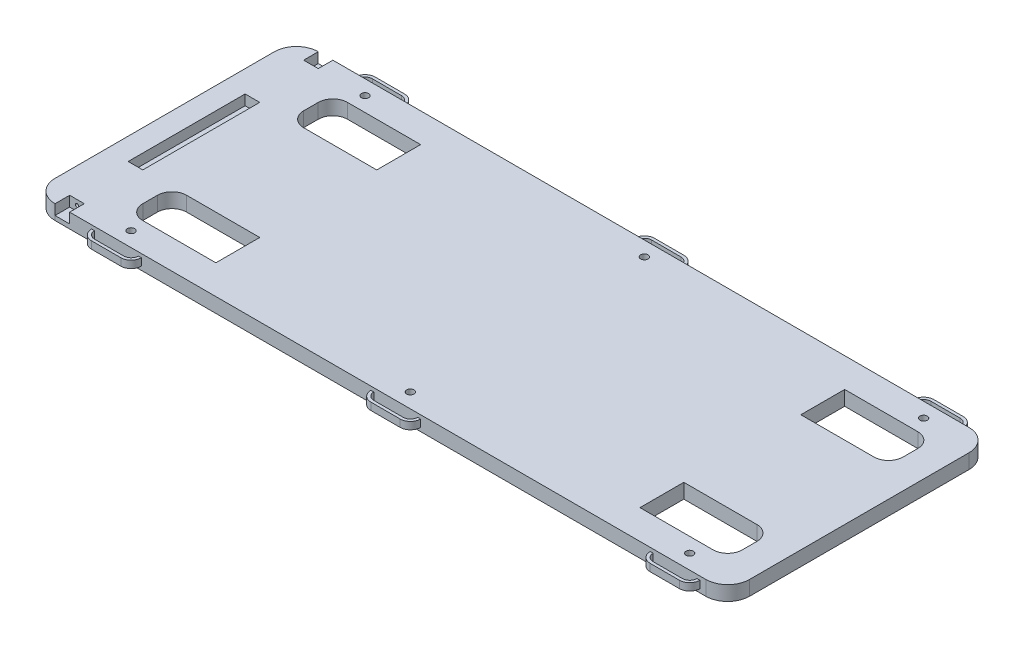
from build123d import *

# Parameters (mm, degrees)
BOSS_EXTRUDE1_DEPTH     = 12.7
BACKREST_BRACKET_SLOT_W = 12.7
BACKREST_BRACKET_SLOT_H = 8.89
CUT_EXTRUDE3_DEPTH      = 12.7
BACKREST_SCREW_HOLE_R   = 1.397
CUT_EXTRUDE4_DEPTH      = 6.35
CUT_EXTRUDE5_DEPTH      = 25.4
BOSS_EXTRUDE2_DEPTH     = 3.175
SKETCH37_W              = 12.7
SKETCH37_H              = 101.6
CUT_EXTRUDE7_DEPTH      = 8.89
SKETCH38_R              = 3.175
CUT_EXTRUDE8_DEPTH      = 12.7


with BuildPart() as part:
    # Main Body → Boss-Extrude1 (new body)
    with BuildSketch(Plane(origin=(0, 0, 0), x_dir=(1, 0, 0), z_dir=(0, 1, 0))):
        with BuildLine():
            Line((-301.625, -95.25), (-301.625, 95.25))
            ThreePointArc((-301.625, 95.25), (-296.045384182, 108.720384182), (-282.575, 114.3))
            Line((-282.575, 114.3), (282.575, 114.3))
            ThreePointArc((282.575, 114.3), (296.045384182, 108.720384182), (301.625, 95.25))
            Line((301.625, 95.25), (301.625, -95.25))
            ThreePointArc((301.625, -95.25), (296.045384182, -108.720384182), (282.575, -114.3))
            Line((282.575, -114.3), (-282.575, -114.3))
            ThreePointArc((-282.575, -114.3), (-296.045384182, -108.720384182), (-301.625, -95.25))
        make_face()
    extrude(amount=BOSS_EXTRUDE1_DEPTH)

    # Backrest Bracket Slot → Cut-Extrude3 (cut)
    with BuildSketch(Plane.XY.offset(114.3)):
        with Locations((-276.225, 8.255)):
            Rectangle(BACKREST_BRACKET_SLOT_W, BACKREST_BRACKET_SLOT_H)
    cut_extrude3 = extrude(amount=-CUT_EXTRUDE3_DEPTH, mode=Mode.SUBTRACT)

    # Backrest Screw Hole → Cut-Extrude4 (cut)
    with BuildSketch(Plane.XY.offset(101.6)):
        with Locations((-276.225, 8.255)):
            Circle(BACKREST_SCREW_HOLE_R)
    cut_extrude4 = extrude(amount=-CUT_EXTRUDE4_DEPTH, mode=Mode.SUBTRACT)

    # Mirror1: Cut-Extrude3, Cut-Extrude4 across plane
    add(cut_extrude3.mirror(Plane.XY), mode=Mode.SUBTRACT)
    add(cut_extrude4.mirror(Plane.XY), mode=Mode.SUBTRACT)

    # Couch Foot Slits → Cut-Extrude5 (cut)
    with BuildSketch(Plane(origin=(0, 12.7, 0), x_dir=(1, 0, 0), z_dir=(0, 1, 0))):
        with BuildLine():
            Line((-231.775, 88.9), (-168.275, 88.9))
            Line((-168.275, 88.9), (-168.275, 50.8))
            Line((-168.275, 50.8), (-231.775, 50.8))
            ThreePointArc((-231.775, 50.8), (-240.755256121, 54.519743879), (-244.475, 63.5))
            Line((-244.475, 63.5), (-244.475, 76.2))
            ThreePointArc((-244.475, 76.2), (-240.755256121, 85.180256121), (-231.775, 88.9))
        make_face()
        with BuildLine():
            Line((276.225, 76.2), (276.225, 63.5))
            ThreePointArc((276.225, 63.5), (272.505256121, 54.519743879), (263.525, 50.8))
            Line((263.525, 50.8), (200.025, 50.8))
            Line((200.025, 50.8), (200.025, 88.9))
            Line((200.025, 88.9), (263.525, 88.9))
            ThreePointArc((263.525, 88.9), (272.505256121, 85.180256121), (276.225, 76.2))
        make_face()
        with BuildLine():
            Line((-231.775, -50.8), (-168.275, -50.8))
            Line((-168.275, -50.8), (-168.275, -88.9))
            Line((-168.275, -88.9), (-231.775, -88.9))
            ThreePointArc((-231.775, -88.9), (-240.755256121, -85.180256121), (-244.475, -76.2))
            Line((-244.475, -76.2), (-244.475, -63.5))
            ThreePointArc((-244.475, -63.5), (-240.755256121, -54.519743879), (-231.775, -50.8))
        make_face()
        with BuildLine():
            Line((276.225, -63.5), (276.225, -76.2))
            ThreePointArc((276.225, -76.2), (272.505256121, -85.180256121), (263.525, -88.9))
            Line((263.525, -88.9), (200.025, -88.9))
            Line((200.025, -88.9), (200.025, -50.8))
            Line((200.025, -50.8), (263.525, -50.8))
            ThreePointArc((263.525, -50.8), (272.505256121, -54.519743879), (276.225, -63.5))
        make_face()
    extrude(amount=-CUT_EXTRUDE5_DEPTH, mode=Mode.SUBTRACT)

    # Sketch24 → Boss-Extrude2 (add, symmetric)
    with BuildSketch(Plane(origin=(0, 6.35, 0), x_dir=(1, 0, 0), z_dir=(0, 1, 0))):
        with BuildLine():
            Line((0.635, -120.65), (26.035, -120.65))
            ThreePointArc((26.035, -120.65), (30.525128061, -118.790128061), (32.385, -114.3))
            Line((32.385, -114.3), (34.925, -114.3))
            ThreePointArc((34.925, -114.3), (32.321179285, -120.586179285), (26.035, -123.19))
            Line((26.035, -123.19), (0.635, -123.19))
            ThreePointArc((0.635, -123.19), (-5.651179285, -120.586179285), (-8.255, -114.3))
            Line((-8.255, -114.3), (-5.715, -114.3))
            ThreePointArc((-5.715, -114.3), (-3.855128061, -118.790128061), (0.635, -120.65))
        make_face()
        with BuildLine():
            Line((-241.935, -120.65), (-216.535, -120.65))
            ThreePointArc((-216.535, -120.65), (-212.044871939, -118.790128061), (-210.185, -114.3))
            Line((-210.185, -114.3), (-207.645, -114.3))
            ThreePointArc((-207.645, -114.3), (-210.248820715, -120.586179285), (-216.535, -123.19))
            Line((-216.535, -123.19), (-241.935, -123.19))
            ThreePointArc((-241.935, -123.19), (-248.221179285, -120.586179285), (-250.825, -114.3))
            Line((-250.825, -114.3), (-248.285, -114.3))
            ThreePointArc((-248.285, -114.3), (-246.425128061, -118.790128061), (-241.935, -120.65))
        make_face()
        with BuildLine():
            Line((243.205, -120.65), (268.605, -120.65))
            ThreePointArc((268.605, -120.65), (273.095128061, -118.790128061), (274.955, -114.3))
            Line((274.955, -114.3), (277.495, -114.3))
            ThreePointArc((277.495, -114.3), (274.891179285, -120.586179285), (268.605, -123.19))
            Line((268.605, -123.19), (243.205, -123.19))
            ThreePointArc((243.205, -123.19), (236.918820715, -120.586179285), (234.315, -114.3))
            Line((234.315, -114.3), (236.855, -114.3))
            ThreePointArc((236.855, -114.3), (238.714871939, -118.790128061), (243.205, -120.65))
        make_face()
    boss_extrude2 = extrude(amount=BOSS_EXTRUDE2_DEPTH, both=True)

    # Mirror2: Boss-Extrude2 across plane
    add(boss_extrude2.mirror(Plane.XY))

    # Sketch37 → Cut-Extrude7 (cut)
    with BuildSketch(Plane(origin=(0, 12.7, 0), x_dir=(1, 0, 0), z_dir=(0, 1, 0))):
        with Locations((-276.225, 0)):
            Rectangle(SKETCH37_W, SKETCH37_H)
    extrude(amount=-CUT_EXTRUDE7_DEPTH, mode=Mode.SUBTRACT)

    # Sketch38 → Cut-Extrude8 (cut)
    with BuildSketch(Plane(origin=(0, 12.7, 0), x_dir=(1, 0, 0), z_dir=(0, 1, 0))):
        with Locations((-229.235, -101.6)):
            Circle(SKETCH38_R)
        with Locations((13.335, -101.6)):
            Circle(SKETCH38_R)
        with Locations((255.905, -101.6)):
            Circle(SKETCH38_R)
    cut_extrude8 = extrude(amount=-CUT_EXTRUDE8_DEPTH, mode=Mode.SUBTRACT)

    # Mirror3: Cut-Extrude8 across plane
    add(cut_extrude8.mirror(Plane.XY), mode=Mode.SUBTRACT)


solid = part.part
